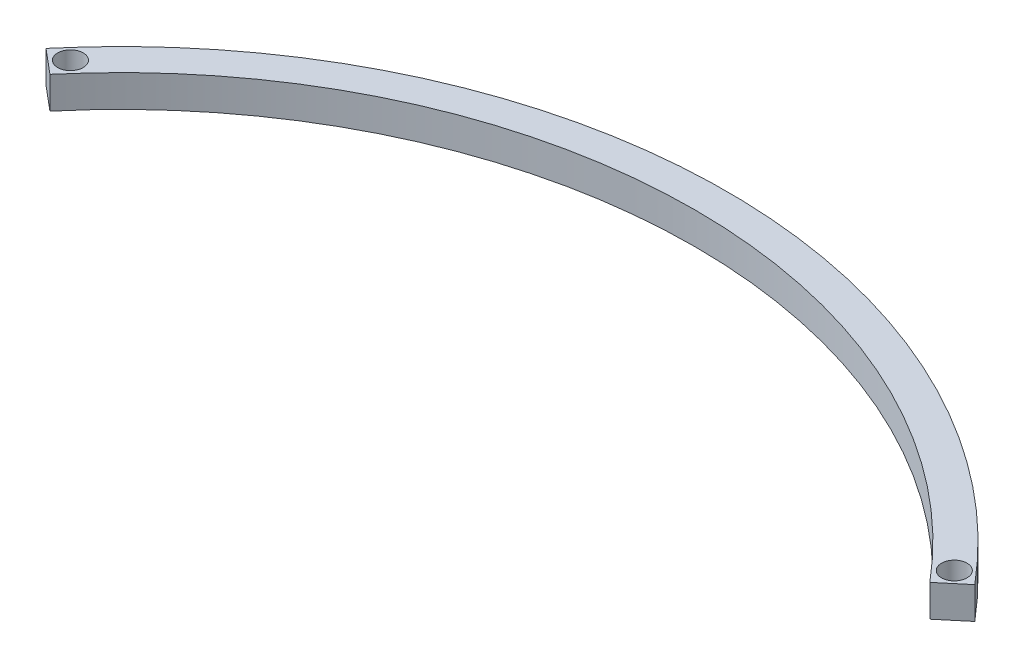
from build123d import *

# Parameters (mm, degrees)
SKETCH1_R           = 4
BOSS_EXTRUDE1_DEPTH = 5


with BuildPart() as part:
    # Sketch1 → Boss-Extrude1 (new body, symmetric)
    with BuildSketch(Plane(origin=(0, 0, 0), x_dir=(1, 0, 0), z_dir=(0, 1, 0))):
        with BuildLine():
            Line((-145.548444193, 122.12964584), (-137.887999761, 115.701769744))
            ThreePointArc((-137.887999761, 115.701769744), (0, 180), (137.887999761, 115.701769744))
            Line((137.887999761, 115.701769744), (145.548444193, 122.12964584))
            ThreePointArc((145.548444193, 122.12964584), (0, 190), (-145.548444193, 122.12964584))
        make_face()
        with Locations((-138.504283929, 122.745930008)):
            Circle(SKETCH1_R, mode=Mode.SUBTRACT)
        with Locations((138.504283929, 122.745930008)):
            Circle(SKETCH1_R, mode=Mode.SUBTRACT)
    extrude(amount=BOSS_EXTRUDE1_DEPTH, both=True)


solid = part.part
